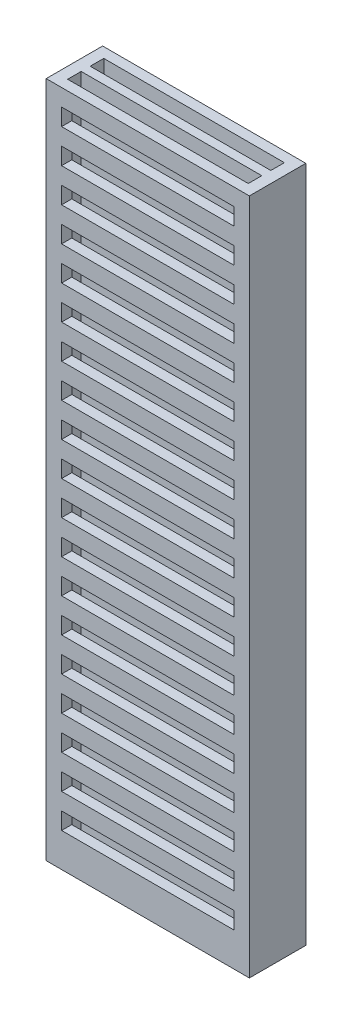
from build123d import *

# Parameters (mm, degrees)
SKETCH1_W                = 9
SKETCH1_H                = 2.5
BOSS_EXTRUDE1_DEPTH      = 15
CUT_EXTRUDE1_START       = -31
SKETCH2_W                = 8
SKETCH2_H                = 0.6
CUT_EXTRUDE1_DEPTH       = 32
SKETCH3_W                = 7.634272068
SKETCH3_H                = 0.75
CUT_EXTRUDE2_DEPTH       = 0.45
LPATTERN1_COUNT          = 19
LPATTERN1_PITCH          = 1.5
MIRROR2_COPY_1_SKETCH_W  = 7.634272068
MIRROR2_COPY_1_SKETCH_H  = 0.75
MIRROR2_COPY_1_DEPTH     = 0.45
MIRROR2_COPY_2_SKETCH_W  = 7.634272068
MIRROR2_COPY_2_SKETCH_H  = 0.75
MIRROR2_COPY_2_DEPTH     = 0.45
MIRROR2_COPY_3_SKETCH_W  = 7.634272068
MIRROR2_COPY_3_SKETCH_H  = 0.75
MIRROR2_COPY_3_DEPTH     = 0.45
MIRROR2_COPY_4_SKETCH_W  = 7.634272068
MIRROR2_COPY_4_SKETCH_H  = 0.75
MIRROR2_COPY_4_DEPTH     = 0.45
MIRROR2_COPY_5_SKETCH_W  = 7.634272068
MIRROR2_COPY_5_SKETCH_H  = 0.75
MIRROR2_COPY_5_DEPTH     = 0.45
MIRROR2_COPY_6_SKETCH_W  = 7.634272068
MIRROR2_COPY_6_SKETCH_H  = 0.75
MIRROR2_COPY_6_DEPTH     = 0.45
MIRROR2_COPY_7_SKETCH_W  = 7.634272068
MIRROR2_COPY_7_SKETCH_H  = 0.75
MIRROR2_COPY_7_DEPTH     = 0.45
MIRROR2_COPY_8_SKETCH_W  = 7.634272068
MIRROR2_COPY_8_SKETCH_H  = 0.75
MIRROR2_COPY_8_DEPTH     = 0.45
MIRROR2_COPY_9_SKETCH_W  = 7.634272068
MIRROR2_COPY_9_SKETCH_H  = 0.75
MIRROR2_COPY_9_DEPTH     = 0.45
MIRROR2_COPY_10_SKETCH_W = 7.634272068
MIRROR2_COPY_10_SKETCH_H = 0.75
MIRROR2_COPY_10_DEPTH    = 0.45
MIRROR2_COPY_11_SKETCH_W = 7.634272068
MIRROR2_COPY_11_SKETCH_H = 0.75
MIRROR2_COPY_11_DEPTH    = 0.45
MIRROR2_COPY_12_SKETCH_W = 7.634272068
MIRROR2_COPY_12_SKETCH_H = 0.75
MIRROR2_COPY_12_DEPTH    = 0.45
MIRROR2_COPY_13_SKETCH_W = 7.634272068
MIRROR2_COPY_13_SKETCH_H = 0.75
MIRROR2_COPY_13_DEPTH    = 0.45
MIRROR2_COPY_14_SKETCH_W = 7.634272068
MIRROR2_COPY_14_SKETCH_H = 0.75
MIRROR2_COPY_14_DEPTH    = 0.45
MIRROR2_COPY_15_SKETCH_W = 7.634272068
MIRROR2_COPY_15_SKETCH_H = 0.75
MIRROR2_COPY_15_DEPTH    = 0.45
MIRROR2_COPY_16_SKETCH_W = 7.634272068
MIRROR2_COPY_16_SKETCH_H = 0.75
MIRROR2_COPY_16_DEPTH    = 0.45
MIRROR2_COPY_17_SKETCH_W = 7.634272068
MIRROR2_COPY_17_SKETCH_H = 0.75
MIRROR2_COPY_17_DEPTH    = 0.45
MIRROR2_COPY_18_SKETCH_W = 7.634272068
MIRROR2_COPY_18_SKETCH_H = 0.75
MIRROR2_COPY_18_DEPTH    = 0.45


with BuildPart() as part:
    # Sketch1 → Boss-Extrude1 (new body, symmetric)
    with BuildSketch(Plane(origin=(0, 0, 0), x_dir=(1, 0, 0), z_dir=(0, 1, 0))):
        Rectangle(SKETCH1_W, SKETCH1_H)
    extrude(amount=BOSS_EXTRUDE1_DEPTH, both=True)

    # Sketch2 → Cut-Extrude1 (cut)
    with BuildSketch(Plane(origin=(0, 15, 0), x_dir=(1, 0, 0), z_dir=(0, 1, 0)).offset(CUT_EXTRUDE1_START)):
        with Locations((0, 0.5)):
            Rectangle(SKETCH2_W, SKETCH2_H)
    cut_extrude1 = extrude(amount=CUT_EXTRUDE1_DEPTH, mode=Mode.SUBTRACT)

    # Mirror1: Cut-Extrude1 across plane
    add(cut_extrude1.mirror(Plane.XY), mode=Mode.SUBTRACT)

    # Sketch3 → Cut-Extrude2 (cut)
    with BuildSketch(Plane.XY.offset(1.25)):
        with Locations((0, 13.875)):
            Rectangle(SKETCH3_W, SKETCH3_H)
    cut_extrude2 = extrude(amount=-CUT_EXTRUDE2_DEPTH, mode=Mode.SUBTRACT)

    # LPattern1: Cut-Extrude2 ×19
    with Locations(*[(0, -i * LPATTERN1_PITCH, 0) for i in range(1, LPATTERN1_COUNT)]):
        add(cut_extrude2, mode=Mode.SUBTRACT)

    # Mirror2: Cut-Extrude2 across plane
    add(cut_extrude2.mirror(Plane.XY), mode=Mode.SUBTRACT)

    # Mirror2 copy 1 sketch → Mirror2 copy 1 (cut)
    with BuildSketch(Plane(origin=(0, -1.5, -1.25), x_dir=(1, 0, 0), z_dir=(0, 0, -1))):
        with Locations((0, -13.875)):
            Rectangle(MIRROR2_COPY_1_SKETCH_W, MIRROR2_COPY_1_SKETCH_H)
    extrude(amount=-MIRROR2_COPY_1_DEPTH, mode=Mode.SUBTRACT)

    # Mirror2 copy 2 sketch → Mirror2 copy 2 (cut)
    with BuildSketch(Plane(origin=(0, -3, -1.25), x_dir=(1, 0, 0), z_dir=(0, 0, -1))):
        with Locations((0, -13.875)):
            Rectangle(MIRROR2_COPY_2_SKETCH_W, MIRROR2_COPY_2_SKETCH_H)
    extrude(amount=-MIRROR2_COPY_2_DEPTH, mode=Mode.SUBTRACT)

    # Mirror2 copy 3 sketch → Mirror2 copy 3 (cut)
    with BuildSketch(Plane(origin=(0, -4.5, -1.25), x_dir=(1, 0, 0), z_dir=(0, 0, -1))):
        with Locations((0, -13.875)):
            Rectangle(MIRROR2_COPY_3_SKETCH_W, MIRROR2_COPY_3_SKETCH_H)
    extrude(amount=-MIRROR2_COPY_3_DEPTH, mode=Mode.SUBTRACT)

    # Mirror2 copy 4 sketch → Mirror2 copy 4 (cut)
    with BuildSketch(Plane(origin=(0, -6, -1.25), x_dir=(1, 0, 0), z_dir=(0, 0, -1))):
        with Locations((0, -13.875)):
            Rectangle(MIRROR2_COPY_4_SKETCH_W, MIRROR2_COPY_4_SKETCH_H)
    extrude(amount=-MIRROR2_COPY_4_DEPTH, mode=Mode.SUBTRACT)

    # Mirror2 copy 5 sketch → Mirror2 copy 5 (cut)
    with BuildSketch(Plane(origin=(0, -7.5, -1.25), x_dir=(1, 0, 0), z_dir=(0, 0, -1))):
        with Locations((0, -13.875)):
            Rectangle(MIRROR2_COPY_5_SKETCH_W, MIRROR2_COPY_5_SKETCH_H)
    extrude(amount=-MIRROR2_COPY_5_DEPTH, mode=Mode.SUBTRACT)

    # Mirror2 copy 6 sketch → Mirror2 copy 6 (cut)
    with BuildSketch(Plane(origin=(0, -9, -1.25), x_dir=(1, 0, 0), z_dir=(0, 0, -1))):
        with Locations((0, -13.875)):
            Rectangle(MIRROR2_COPY_6_SKETCH_W, MIRROR2_COPY_6_SKETCH_H)
    extrude(amount=-MIRROR2_COPY_6_DEPTH, mode=Mode.SUBTRACT)

    # Mirror2 copy 7 sketch → Mirror2 copy 7 (cut)
    with BuildSketch(Plane(origin=(0, -10.5, -1.25), x_dir=(1, 0, 0), z_dir=(0, 0, -1))):
        with Locations((0, -13.875)):
            Rectangle(MIRROR2_COPY_7_SKETCH_W, MIRROR2_COPY_7_SKETCH_H)
    extrude(amount=-MIRROR2_COPY_7_DEPTH, mode=Mode.SUBTRACT)

    # Mirror2 copy 8 sketch → Mirror2 copy 8 (cut)
    with BuildSketch(Plane(origin=(0, -12, -1.25), x_dir=(1, 0, 0), z_dir=(0, 0, -1))):
        with Locations((0, -13.875)):
            Rectangle(MIRROR2_COPY_8_SKETCH_W, MIRROR2_COPY_8_SKETCH_H)
    extrude(amount=-MIRROR2_COPY_8_DEPTH, mode=Mode.SUBTRACT)

    # Mirror2 copy 9 sketch → Mirror2 copy 9 (cut)
    with BuildSketch(Plane(origin=(0, -13.5, -1.25), x_dir=(1, 0, 0), z_dir=(0, 0, -1))):
        with Locations((0, -13.875)):
            Rectangle(MIRROR2_COPY_9_SKETCH_W, MIRROR2_COPY_9_SKETCH_H)
    extrude(amount=-MIRROR2_COPY_9_DEPTH, mode=Mode.SUBTRACT)

    # Mirror2 copy 10 sketch → Mirror2 copy 10 (cut)
    with BuildSketch(Plane(origin=(0, -15, -1.25), x_dir=(1, 0, 0), z_dir=(0, 0, -1))):
        with Locations((0, -13.875)):
            Rectangle(MIRROR2_COPY_10_SKETCH_W, MIRROR2_COPY_10_SKETCH_H)
    extrude(amount=-MIRROR2_COPY_10_DEPTH, mode=Mode.SUBTRACT)

    # Mirror2 copy 11 sketch → Mirror2 copy 11 (cut)
    with BuildSketch(Plane(origin=(0, -16.5, -1.25), x_dir=(1, 0, 0), z_dir=(0, 0, -1))):
        with Locations((0, -13.875)):
            Rectangle(MIRROR2_COPY_11_SKETCH_W, MIRROR2_COPY_11_SKETCH_H)
    extrude(amount=-MIRROR2_COPY_11_DEPTH, mode=Mode.SUBTRACT)

    # Mirror2 copy 12 sketch → Mirror2 copy 12 (cut)
    with BuildSketch(Plane(origin=(0, -18, -1.25), x_dir=(1, 0, 0), z_dir=(0, 0, -1))):
        with Locations((0, -13.875)):
            Rectangle(MIRROR2_COPY_12_SKETCH_W, MIRROR2_COPY_12_SKETCH_H)
    extrude(amount=-MIRROR2_COPY_12_DEPTH, mode=Mode.SUBTRACT)

    # Mirror2 copy 13 sketch → Mirror2 copy 13 (cut)
    with BuildSketch(Plane(origin=(0, -19.5, -1.25), x_dir=(1, 0, 0), z_dir=(0, 0, -1))):
        with Locations((0, -13.875)):
            Rectangle(MIRROR2_COPY_13_SKETCH_W, MIRROR2_COPY_13_SKETCH_H)
    extrude(amount=-MIRROR2_COPY_13_DEPTH, mode=Mode.SUBTRACT)

    # Mirror2 copy 14 sketch → Mirror2 copy 14 (cut)
    with BuildSketch(Plane(origin=(0, -21, -1.25), x_dir=(1, 0, 0), z_dir=(0, 0, -1))):
        with Locations((0, -13.875)):
            Rectangle(MIRROR2_COPY_14_SKETCH_W, MIRROR2_COPY_14_SKETCH_H)
    extrude(amount=-MIRROR2_COPY_14_DEPTH, mode=Mode.SUBTRACT)

    # Mirror2 copy 15 sketch → Mirror2 copy 15 (cut)
    with BuildSketch(Plane(origin=(0, -22.5, -1.25), x_dir=(1, 0, 0), z_dir=(0, 0, -1))):
        with Locations((0, -13.875)):
            Rectangle(MIRROR2_COPY_15_SKETCH_W, MIRROR2_COPY_15_SKETCH_H)
    extrude(amount=-MIRROR2_COPY_15_DEPTH, mode=Mode.SUBTRACT)

    # Mirror2 copy 16 sketch → Mirror2 copy 16 (cut)
    with BuildSketch(Plane(origin=(0, -24, -1.25), x_dir=(1, 0, 0), z_dir=(0, 0, -1))):
        with Locations((0, -13.875)):
            Rectangle(MIRROR2_COPY_16_SKETCH_W, MIRROR2_COPY_16_SKETCH_H)
    extrude(amount=-MIRROR2_COPY_16_DEPTH, mode=Mode.SUBTRACT)

    # Mirror2 copy 17 sketch → Mirror2 copy 17 (cut)
    with BuildSketch(Plane(origin=(0, -25.5, -1.25), x_dir=(1, 0, 0), z_dir=(0, 0, -1))):
        with Locations((0, -13.875)):
            Rectangle(MIRROR2_COPY_17_SKETCH_W, MIRROR2_COPY_17_SKETCH_H)
    extrude(amount=-MIRROR2_COPY_17_DEPTH, mode=Mode.SUBTRACT)

    # Mirror2 copy 18 sketch → Mirror2 copy 18 (cut)
    with BuildSketch(Plane(origin=(0, -27, -1.25), x_dir=(1, 0, 0), z_dir=(0, 0, -1))):
        with Locations((0, -13.875)):
            Rectangle(MIRROR2_COPY_18_SKETCH_W, MIRROR2_COPY_18_SKETCH_H)
    extrude(amount=-MIRROR2_COPY_18_DEPTH, mode=Mode.SUBTRACT)


solid = part.part
